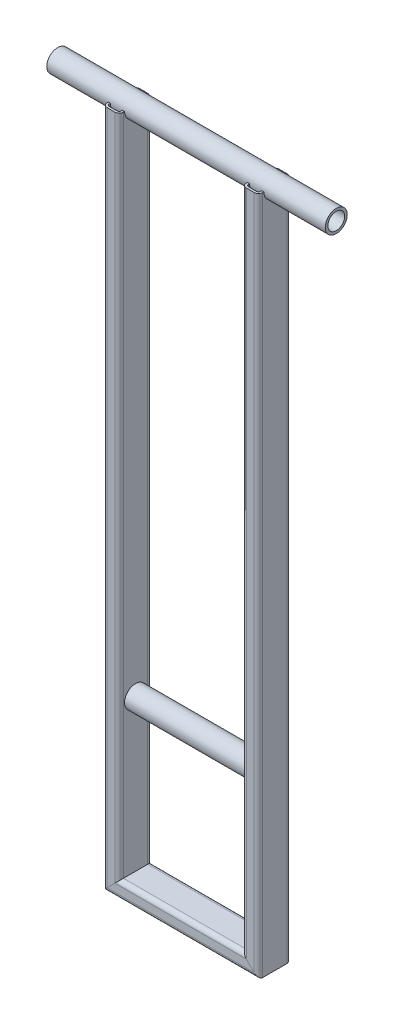
from build123d import *

# Parameters (mm, degrees)
SKETCH11_R                               = 13.45
SKETCH11_R_2                             = 10.25
PIPE_26_9_X_3_2_1_DEPTH                  = 340
SKETCH11_ON_SEGMENT_2_R                  = 13.45
SKETCH11_ON_SEGMENT_2_R_2                = 10.25
PIPE_26_9_X_3_2_1_2_DEPTH                = 170
RECTANGULAR_TUBE_50_X_30_X_2_6_1_DEPTH   = 820
RECTANGULAR_TUBE_50_X_30_X_2_6_1_2_DEPTH = 820
RECTANGULAR_TUBE_50_X_30_X_2_6_2_DEPTH   = 170
BODY_3_RUN_ON_DEPTH                      = 10
BODY_5_RUN_ON_DEPTH                      = 10
BODY_4_RUN_ON_DEPTH                      = 10
BODY_START                               = 170
BODY_5_RUN_ON_2_DEPTH                    = 10


with BuildPart() as part:
    # Sketch11 → Pipe 26.9 X 3.2(1) (new body)
    with BuildSketch(Plane(origin=(-85, 820, 0), x_dir=(0, 1, 0), z_dir=(1, 0, 0))):
        Circle(SKETCH11_R)
        Circle(SKETCH11_R_2, mode=Mode.SUBTRACT)
    extrude(amount=PIPE_26_9_X_3_2_1_DEPTH)


with BuildPart() as body_2:
    # Sketch11 on segment 2 (carried to segment 2) → Pipe 26.9 X 3.2_1 2 (new body)
    with BuildSketch(Plane(origin=(0, 195, 0), x_dir=(0, 1, 0), z_dir=(1, 0, 0))):
        Circle(SKETCH11_ON_SEGMENT_2_R)
        Circle(SKETCH11_ON_SEGMENT_2_R_2, mode=Mode.SUBTRACT)
    extrude(amount=PIPE_26_9_X_3_2_1_2_DEPTH)


with BuildPart() as body_3:
    # Sketch12 → Rectangular tube 50 X 30 X 2.6(1) (new body)
    with BuildSketch(Plane(origin=(0, 0, 0), x_dir=(-1, 0, 0), z_dir=(0, 1, 0))):
        with BuildLine():
            Line((-4.8, -20), (4.8, -20))
            ThreePointArc((4.8, -20), (8.476955262, -18.476955262), (10, -14.8))
            Line((10, -14.8), (10, 14.8))
            ThreePointArc((10, 14.8), (8.476955262, 18.476955262), (4.8, 20))
            Line((4.8, 20), (-4.8, 20))
            ThreePointArc((-4.8, 20), (-8.476955262, 18.476955262), (-10, 14.8))
            Line((-10, 14.8), (-10, -14.8))
            ThreePointArc((-10, -14.8), (-8.476955262, -18.476955262), (-4.8, -20))
        make_face()
        with BuildLine():
            Line((-4.8, -17.4), (4.8, -17.4))
            ThreePointArc((4.8, -17.4), (6.638477631, -16.638477631), (7.4, -14.8))
            Line((7.4, -14.8), (7.4, 14.8))
            ThreePointArc((7.4, 14.8), (6.638477631, 16.638477631), (4.8, 17.4))
            Line((4.8, 17.4), (-4.8, 17.4))
            ThreePointArc((-4.8, 17.4), (-6.638477631, 16.638477631), (-7.4, 14.8))
            Line((-7.4, 14.8), (-7.4, -14.8))
            ThreePointArc((-7.4, -14.8), (-6.638477631, -16.638477631), (-4.8, -17.4))
        make_face(mode=Mode.SUBTRACT)
    extrude(amount=RECTANGULAR_TUBE_50_X_30_X_2_6_1_DEPTH)

    # Sketch12 → body 3 run on (add)
    with BuildSketch(Plane(origin=(0, 0, 0), x_dir=(-1, 0, 0), z_dir=(0, 1, 0))):
        with BuildLine():
            Line((-4.8, -20), (4.8, -20))
            ThreePointArc((4.8, -20), (8.476955262, -18.476955262), (10, -14.8))
            Line((10, -14.8), (10, 14.8))
            ThreePointArc((10, 14.8), (8.476955262, 18.476955262), (4.8, 20))
            Line((4.8, 20), (-4.8, 20))
            ThreePointArc((-4.8, 20), (-8.476955262, 18.476955262), (-10, 14.8))
            Line((-10, 14.8), (-10, -14.8))
            ThreePointArc((-10, -14.8), (-8.476955262, -18.476955262), (-4.8, -20))
        make_face()
        with BuildLine():
            Line((-4.8, -17.4), (4.8, -17.4))
            ThreePointArc((4.8, -17.4), (6.638477631, -16.638477631), (7.4, -14.8))
            Line((7.4, -14.8), (7.4, 14.8))
            ThreePointArc((7.4, 14.8), (6.638477631, 16.638477631), (4.8, 17.4))
            Line((4.8, 17.4), (-4.8, 17.4))
            ThreePointArc((-4.8, 17.4), (-6.638477631, 16.638477631), (-7.4, 14.8))
            Line((-7.4, 14.8), (-7.4, -14.8))
            ThreePointArc((-7.4, -14.8), (-6.638477631, -16.638477631), (-4.8, -17.4))
        make_face(mode=Mode.SUBTRACT)
    extrude(amount=-BODY_3_RUN_ON_DEPTH)

    # Trim/Extend1
    split(bisect_by=Plane(origin=(0, 0, 0), x_dir=(-0.707106781, -0.707106781, 0), z_dir=(-0.707106781, 0.707106781, 0)), keep=Keep.TOP)

    # Trim/Extend4: cut back where it meets the other member's skin (coped)
    split(bisect_by=part.part.faces().sort_by_distance((85, 806.55, 0))[0], keep=Keep.TOP)


with BuildPart() as body_4:
    # Sketch12 on segment 2 (carried to segment 2) → Rectangular tube 50 X 30 X 2.6_1 2 (new body)
    with BuildSketch(Plane(origin=(170, 0, 0), x_dir=(-1, 0, 0), z_dir=(0, 1, 0))):
        with BuildLine():
            Line((-4.8, -20), (4.8, -20))
            ThreePointArc((4.8, -20), (8.476955262, -18.476955262), (10, -14.8))
            Line((10, -14.8), (10, 14.8))
            ThreePointArc((10, 14.8), (8.476955262, 18.476955262), (4.8, 20))
            Line((4.8, 20), (-4.8, 20))
            ThreePointArc((-4.8, 20), (-8.476955262, 18.476955262), (-10, 14.8))
            Line((-10, 14.8), (-10, -14.8))
            ThreePointArc((-10, -14.8), (-8.476955262, -18.476955262), (-4.8, -20))
        make_face()
        with BuildLine():
            Line((-4.8, -17.4), (4.8, -17.4))
            ThreePointArc((4.8, -17.4), (6.638477631, -16.638477631), (7.4, -14.8))
            Line((7.4, -14.8), (7.4, 14.8))
            ThreePointArc((7.4, 14.8), (6.638477631, 16.638477631), (4.8, 17.4))
            Line((4.8, 17.4), (-4.8, 17.4))
            ThreePointArc((-4.8, 17.4), (-6.638477631, 16.638477631), (-7.4, 14.8))
            Line((-7.4, 14.8), (-7.4, -14.8))
            ThreePointArc((-7.4, -14.8), (-6.638477631, -16.638477631), (-4.8, -17.4))
        make_face(mode=Mode.SUBTRACT)
    extrude(amount=RECTANGULAR_TUBE_50_X_30_X_2_6_1_2_DEPTH)

    # Sketch12 on segment 2 (carried to segment 2) → body 4 run on (add)
    with BuildSketch(Plane(origin=(170, 0, 0), x_dir=(-1, 0, 0), z_dir=(0, 1, 0))):
        with BuildLine():
            Line((-4.8, -20), (4.8, -20))
            ThreePointArc((4.8, -20), (8.476955262, -18.476955262), (10, -14.8))
            Line((10, -14.8), (10, 14.8))
            ThreePointArc((10, 14.8), (8.476955262, 18.476955262), (4.8, 20))
            Line((4.8, 20), (-4.8, 20))
            ThreePointArc((-4.8, 20), (-8.476955262, 18.476955262), (-10, 14.8))
            Line((-10, 14.8), (-10, -14.8))
            ThreePointArc((-10, -14.8), (-8.476955262, -18.476955262), (-4.8, -20))
        make_face()
        with BuildLine():
            Line((-4.8, -17.4), (4.8, -17.4))
            ThreePointArc((4.8, -17.4), (6.638477631, -16.638477631), (7.4, -14.8))
            Line((7.4, -14.8), (7.4, 14.8))
            ThreePointArc((7.4, 14.8), (6.638477631, 16.638477631), (4.8, 17.4))
            Line((4.8, 17.4), (-4.8, 17.4))
            ThreePointArc((-4.8, 17.4), (-6.638477631, 16.638477631), (-7.4, 14.8))
            Line((-7.4, 14.8), (-7.4, -14.8))
            ThreePointArc((-7.4, -14.8), (-6.638477631, -16.638477631), (-4.8, -17.4))
        make_face(mode=Mode.SUBTRACT)
    extrude(amount=-BODY_4_RUN_ON_DEPTH)

    # Trim/Extend2
    split(bisect_by=Plane(origin=(170, 0, 0), x_dir=(-0.707106781, 0.707106781, 0), z_dir=(0.707106781, 0.707106781, 0)), keep=Keep.TOP)

    # Trim/Extend4: cut back where it meets the other member's skin (coped)
    split(bisect_by=part.part.faces().sort_by_distance((85, 806.55, 0))[0], keep=Keep.TOP)


with BuildPart() as body_5:
    # Sketch13 → Rectangular tube 50 X 30 X 2.6(2) (new body)
    with BuildSketch(Plane.YZ):
        with BuildLine():
            Line((-4.8, -20), (4.8, -20))
            ThreePointArc((4.8, -20), (8.476955262, -18.476955262), (10, -14.8))
            Line((10, -14.8), (10, 14.8))
            ThreePointArc((10, 14.8), (8.476955262, 18.476955262), (4.8, 20))
            Line((4.8, 20), (-4.8, 20))
            ThreePointArc((-4.8, 20), (-8.476955262, 18.476955262), (-10, 14.8))
            Line((-10, 14.8), (-10, -14.8))
            ThreePointArc((-10, -14.8), (-8.476955262, -18.476955262), (-4.8, -20))
        make_face()
        with BuildLine():
            Line((-4.8, -17.4), (4.8, -17.4))
            ThreePointArc((4.8, -17.4), (6.638477631, -16.638477631), (7.4, -14.8))
            Line((7.4, -14.8), (7.4, 14.8))
            ThreePointArc((7.4, 14.8), (6.638477631, 16.638477631), (4.8, 17.4))
            Line((4.8, 17.4), (-4.8, 17.4))
            ThreePointArc((-4.8, 17.4), (-6.638477631, 16.638477631), (-7.4, 14.8))
            Line((-7.4, 14.8), (-7.4, -14.8))
            ThreePointArc((-7.4, -14.8), (-6.638477631, -16.638477631), (-4.8, -17.4))
        make_face(mode=Mode.SUBTRACT)
    extrude(amount=RECTANGULAR_TUBE_50_X_30_X_2_6_2_DEPTH)

    # Sketch13 → body 5 run on (add)
    with BuildSketch(Plane.YZ):
        with BuildLine():
            Line((-4.8, -20), (4.8, -20))
            ThreePointArc((4.8, -20), (8.476955262, -18.476955262), (10, -14.8))
            Line((10, -14.8), (10, 14.8))
            ThreePointArc((10, 14.8), (8.476955262, 18.476955262), (4.8, 20))
            Line((4.8, 20), (-4.8, 20))
            ThreePointArc((-4.8, 20), (-8.476955262, 18.476955262), (-10, 14.8))
            Line((-10, 14.8), (-10, -14.8))
            ThreePointArc((-10, -14.8), (-8.476955262, -18.476955262), (-4.8, -20))
        make_face()
        with BuildLine():
            Line((-4.8, -17.4), (4.8, -17.4))
            ThreePointArc((4.8, -17.4), (6.638477631, -16.638477631), (7.4, -14.8))
            Line((7.4, -14.8), (7.4, 14.8))
            ThreePointArc((7.4, 14.8), (6.638477631, 16.638477631), (4.8, 17.4))
            Line((4.8, 17.4), (-4.8, 17.4))
            ThreePointArc((-4.8, 17.4), (-6.638477631, 16.638477631), (-7.4, 14.8))
            Line((-7.4, 14.8), (-7.4, -14.8))
            ThreePointArc((-7.4, -14.8), (-6.638477631, -16.638477631), (-4.8, -17.4))
        make_face(mode=Mode.SUBTRACT)
    extrude(amount=-BODY_5_RUN_ON_DEPTH)

    # Trim/Extend1
    split(bisect_by=Plane(origin=(0, 0, 0), x_dir=(0.707106781, 0.707106781, 0), z_dir=(0.707106781, -0.707106781, 0)), keep=Keep.TOP)

    # Sketch13 → body 5 run on 2 (add)
    with BuildSketch(Plane.YZ.offset(BODY_START)):
        with BuildLine():
            Line((-4.8, -20), (4.8, -20))
            ThreePointArc((4.8, -20), (8.476955262, -18.476955262), (10, -14.8))
            Line((10, -14.8), (10, 14.8))
            ThreePointArc((10, 14.8), (8.476955262, 18.476955262), (4.8, 20))
            Line((4.8, 20), (-4.8, 20))
            ThreePointArc((-4.8, 20), (-8.476955262, 18.476955262), (-10, 14.8))
            Line((-10, 14.8), (-10, -14.8))
            ThreePointArc((-10, -14.8), (-8.476955262, -18.476955262), (-4.8, -20))
        make_face()
        with BuildLine():
            Line((-4.8, -17.4), (4.8, -17.4))
            ThreePointArc((4.8, -17.4), (6.638477631, -16.638477631), (7.4, -14.8))
            Line((7.4, -14.8), (7.4, 14.8))
            ThreePointArc((7.4, 14.8), (6.638477631, 16.638477631), (4.8, 17.4))
            Line((4.8, 17.4), (-4.8, 17.4))
            ThreePointArc((-4.8, 17.4), (-6.638477631, 16.638477631), (-7.4, 14.8))
            Line((-7.4, 14.8), (-7.4, -14.8))
            ThreePointArc((-7.4, -14.8), (-6.638477631, -16.638477631), (-4.8, -17.4))
        make_face(mode=Mode.SUBTRACT)
    extrude(amount=BODY_5_RUN_ON_2_DEPTH)

    # Trim/Extend2
    split(bisect_by=Plane(origin=(170, 0, 0), x_dir=(0.707106781, -0.707106781, 0), z_dir=(-0.707106781, -0.707106781, 0)), keep=Keep.TOP)


solid = Compound([part.part, body_2.part, body_3.part, body_4.part, body_5.part])
